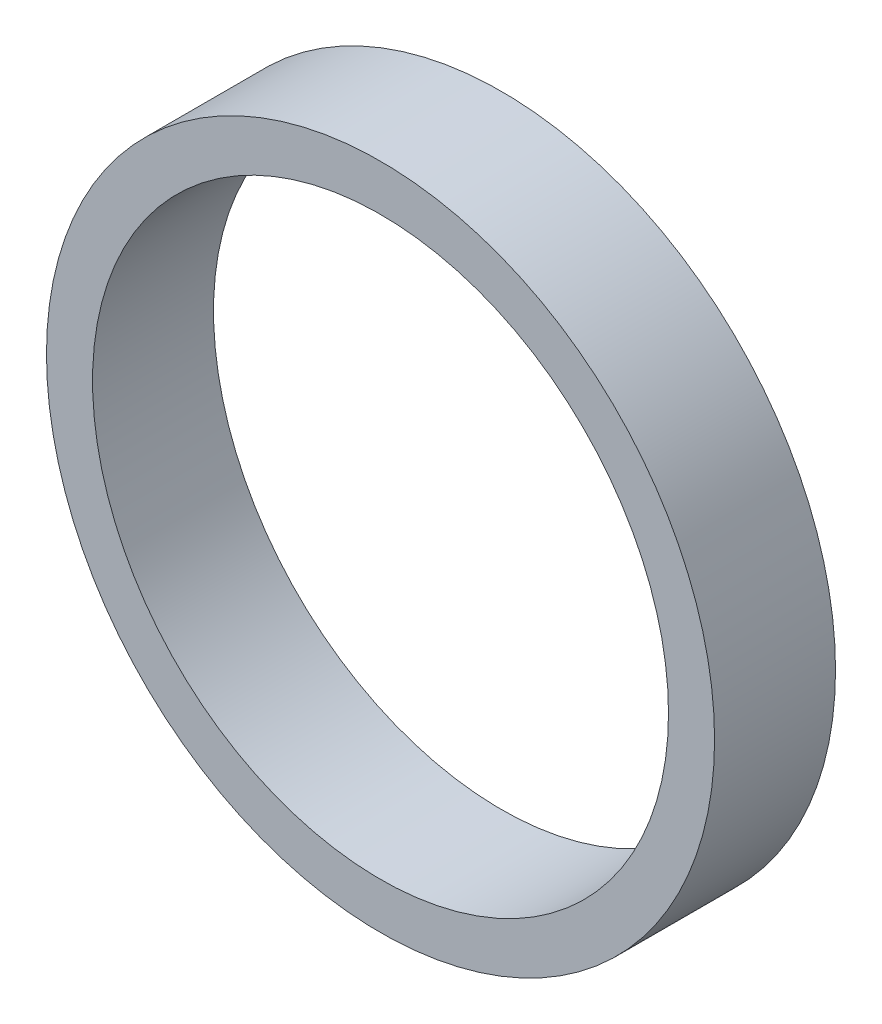
from build123d import *

# Parameters (mm, degrees)
ESQUISSE1_R        = 14.5
ESQUISSE1_R_2      = 12.5
BOSS_EXTRU_1_DEPTH = 5.25


with BuildPart() as part:
    # Esquisse1 → Boss.-Extru.1 (new body)
    with BuildSketch(Plane.XY):
        Circle(ESQUISSE1_R)
        Circle(ESQUISSE1_R_2, mode=Mode.SUBTRACT)
    extrude(amount=BOSS_EXTRU_1_DEPTH)


solid = part.part
